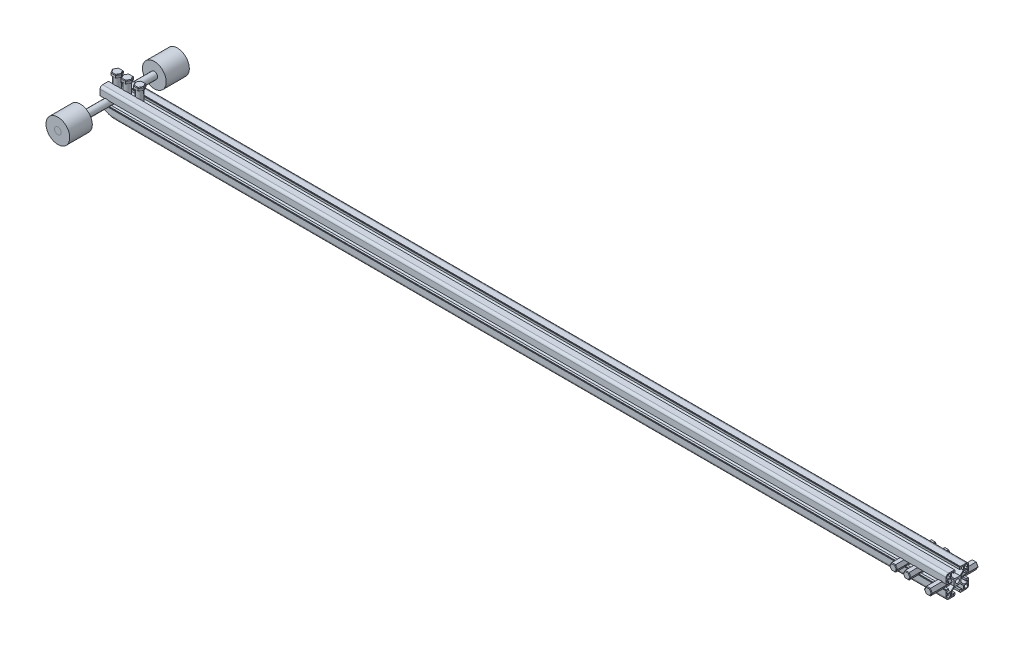
from build123d import *

# Parameters (mm, degrees)
SKETCH11_R                                     = 3.4
C_PROGRAM_FILES_SOLIDWORKS_CORP_SOLIDWOR_DEPTH = 2000
IZIM1_R                                        = 66.227131851
KES_EKSTR_ZYON1_DEPTH                          = 500
Y_KSEKLIK_EKSTR_ZYON2_START                    = -48
Y_KSEKLIK_EKSTR_ZYON2_DEPTH                    = 83
IZIM5_R                                        = 1
KES_EKSTR_ZYON2_DEPTH                          = 75
IZIM6_R                                        = 5.5
Y_KSEKLIK_EKSTR_ZYON3_DEPTH                    = 30
Y_KSEKLIK_EKSTR_ZYON4_START                    = -3
Y_KSEKLIK_EKSTR_ZYON4_DEPTH                    = 5
PAH1_SIZE                                      = 1
KES_EKSTR_ZYON3_DEPTH                          = 77
L_O_ALTMA1_COUNT                               = 2
L_O_ALTMA1_PITCH                               = 18
PAH2_SIZE                                      = 1
L_O_ALTMA2_COUNT                               = 2
L_O_ALTMA2_PITCH                               = 18
IZIM2_R                                        = 6
Y_KSEKLIK_EKSTR_ZYON5_DEPTH                    = 100
Y_KSEKLIK_EKSTR_ZYON5_DEPTH_BACK               = 112
Y_KSEKLIK_EKSTR_ZYON6_DEPTH                    = 30
Y_KSEKLIK_EKSTR_ZYON6_DEPTH_BACK               = 42
Y_KSEKLIK_EKSTR_ZYON6_2_DEPTH                  = 30
Y_KSEKLIK_EKSTR_ZYON6_2_DEPTH_BACK             = 42
PAH4_SIZE                                      = 1
PAH5_SIZE                                      = 1
PAH6_SIZE                                      = 1
PAH7_SIZE                                      = 1
PAH8_SIZE                                      = 1
IZIM10_R                                       = 21.05967532
Y_KSEKLIK_EKSTR_ZYON7_DEPTH                    = 41
IZIM11_R                                       = 21.05967532
Y_KSEKLIK_EKSTR_ZYON8_DEPTH                    = 40
L_O_ALTMA4_COUNT                               = 2
L_O_ALTMA4_PITCH                               = 40
L_O_ALTMA5_COUNT                               = 2
L_O_ALTMA5_PITCH                               = 40
PAH9_SIZE                                      = 1


with BuildPart() as part:
    # Sketch11 → C_PROGRAM FILES_SOLIDWORKS CORP_SOLIDWOR (new body)
    with BuildSketch(Plane.YZ):
        with BuildLine():
            Line((-6.137886111, 5.937531511), (3.033686764, 5.937531511))
            Line((3.033686764, 5.937531511), (8.847900326, 11.751745073))
            Line((8.847900326, 11.751745073), (8.847900326, 18.137531511))
            Line((8.847900326, 18.137531511), (5.706014433, 18.137531511))
            Line((5.706014433, 18.137531511), (5.706014433, 15.437531511))
            Line((5.706014433, 15.437531511), (2.547900326, 15.437531511))
            Line((2.547900326, 15.437531511), (2.547900326, 18.937531511))
            Line((2.547900326, 18.937531511), (3.547900326, 18.937531511))
            Line((3.547900326, 18.937531511), (3.547900326, 19.937531511))
            Line((3.547900326, 19.937531511), (13.947900326, 19.937531511))
            ThreePointArc((13.947900326, 19.937531511), (17.129880842, 18.619512026), (18.447900326, 15.437531511))
            Line((18.447900326, 15.437531511), (18.447900326, 5.037531511))
            Line((18.447900326, 5.037531511), (17.447900326, 5.037531511))
            Line((17.447900326, 5.037531511), (17.447900326, 4.037531511))
            Line((17.447900326, 4.037531511), (13.947900326, 4.037531511))
            Line((13.947900326, 4.037531511), (13.947900326, 7.037531511))
            Line((13.947900326, 7.037531511), (16.647900326, 7.037531511))
            Line((16.647900326, 7.037531511), (16.647900326, 10.337531511))
            Line((16.647900326, 10.337531511), (10.262113889, 10.337531511))
            Line((10.262113889, 10.337531511), (4.447900326, 4.523317948))
            Line((4.447900326, 4.523317948), (4.447900326, -4.648254927))
            Line((4.447900326, -4.648254927), (10.262113889, -10.462468489))
            Line((10.262113889, -10.462468489), (16.647900326, -10.462468489))
            Line((16.647900326, -10.462468489), (16.647900326, -7.162468489))
            Line((16.647900326, -7.162468489), (13.947900326, -7.162468489))
            Line((13.947900326, -7.162468489), (13.947900326, -4.162468489))
            Line((13.947900326, -4.162468489), (17.447900326, -4.162468489))
            Line((17.447900326, -4.162468489), (17.447900326, -5.162468489))
            Line((17.447900326, -5.162468489), (18.447900326, -5.162468489))
            Line((18.447900326, -5.162468489), (18.447900326, -15.562468489))
            ThreePointArc((18.447900326, -15.562468489), (17.129880842, -18.744449005), (13.947900326, -20.062468489))
            Line((13.947900326, -20.062468489), (3.547900326, -20.062468489))
            Line((3.547900326, -20.062468489), (3.547900326, -19.062468489))
            Line((3.547900326, -19.062468489), (2.547900326, -19.062468489))
            Line((2.547900326, -19.062468489), (2.547900326, -15.562468489))
            Line((2.547900326, -15.562468489), (5.706014433, -15.562468489))
            Line((5.706014433, -15.562468489), (5.706014433, -18.262468489))
            Line((5.706014433, -18.262468489), (8.847900326, -18.262468489))
            Line((8.847900326, -18.262468489), (8.847900326, -11.876682052))
            Line((8.847900326, -11.876682052), (3.033686764, -6.062468489))
            Line((3.033686764, -6.062468489), (-6.137886111, -6.062468489))
            Line((-6.137886111, -6.062468489), (-11.952099674, -11.876682052))
            Line((-11.952099674, -11.876682052), (-11.952099674, -18.262468489))
            Line((-11.952099674, -18.262468489), (-8.81021378, -18.262468489))
            Line((-8.81021378, -18.262468489), (-8.81021378, -15.562468489))
            Line((-8.81021378, -15.562468489), (-5.652099674, -15.562468489))
            Line((-5.652099674, -15.562468489), (-5.652099674, -19.062468489))
            Line((-5.652099674, -19.062468489), (-6.652099674, -19.062468489))
            Line((-6.652099674, -19.062468489), (-6.652099674, -20.062468489))
            Line((-6.652099674, -20.062468489), (-17.052099674, -20.062468489))
            ThreePointArc((-17.052099674, -20.062468489), (-20.234080189, -18.744449005), (-21.552099674, -15.562468489))
            Line((-21.552099674, -15.562468489), (-21.552099674, -5.162468489))
            Line((-21.552099674, -5.162468489), (-20.552099674, -5.162468489))
            Line((-20.552099674, -5.162468489), (-20.552099674, -4.162468489))
            Line((-20.552099674, -4.162468489), (-17.052099674, -4.162468489))
            Line((-17.052099674, -4.162468489), (-17.052099674, -7.162468489))
            Line((-17.052099674, -7.162468489), (-19.752099674, -7.162468489))
            Line((-19.752099674, -7.162468489), (-19.752099674, -10.462468489))
            Line((-19.752099674, -10.462468489), (-13.366313236, -10.462468489))
            Line((-13.366313236, -10.462468489), (-7.552099674, -4.648254927))
            Line((-7.552099674, -4.648254927), (-7.552099674, 4.523317948))
            Line((-7.552099674, 4.523317948), (-13.366313236, 10.337531511))
            Line((-13.366313236, 10.337531511), (-19.752099674, 10.337531511))
            Line((-19.752099674, 10.337531511), (-19.752099674, 7.037531511))
            Line((-19.752099674, 7.037531511), (-17.052099674, 7.037531511))
            Line((-17.052099674, 7.037531511), (-17.052099674, 4.037531511))
            Line((-17.052099674, 4.037531511), (-20.552099674, 4.037531511))
            Line((-20.552099674, 4.037531511), (-20.552099674, 5.037531511))
            Line((-20.552099674, 5.037531511), (-21.552099674, 5.037531511))
            Line((-21.552099674, 5.037531511), (-21.552099674, 15.437531511))
            ThreePointArc((-21.552099674, 15.437531511), (-20.234080189, 18.619512026), (-17.052099674, 19.937531511))
            Line((-17.052099674, 19.937531511), (-6.652099674, 19.937531511))
            Line((-6.652099674, 19.937531511), (-6.652099674, 18.937531511))
            Line((-6.652099674, 18.937531511), (-5.652099674, 18.937531511))
            Line((-5.652099674, 18.937531511), (-5.652099674, 15.437531511))
            Line((-5.652099674, 15.437531511), (-8.81021378, 15.437531511))
            Line((-8.81021378, 15.437531511), (-8.81021378, 18.137531511))
            Line((-8.81021378, 18.137531511), (-11.952099674, 18.137531511))
            Line((-11.952099674, 18.137531511), (-11.952099674, 11.751745073))
            Line((-11.952099674, 11.751745073), (-6.137886111, 5.937531511))
        make_face()
        with Locations((-1.552099674, -0.062468489)):
            Circle(SKETCH11_R, mode=Mode.SUBTRACT)
        with BuildLine():
            Line((16.647900326, 12.137531511), (10.647900326, 12.137531511))
            Line((10.647900326, 12.137531511), (10.647900326, 18.137531511))
            Line((10.647900326, 18.137531511), (13.947900326, 18.137531511))
            ThreePointArc((13.947900326, 18.137531511), (15.857088636, 17.34671982), (16.647900326, 15.437531511))
            Line((16.647900326, 15.437531511), (16.647900326, 12.137531511))
        make_face(mode=Mode.SUBTRACT)
        with BuildLine():
            Line((-19.752099674, 15.437531511), (-19.752099674, 12.137531511))
            Line((-19.752099674, 12.137531511), (-13.752099674, 12.137531511))
            Line((-13.752099674, 12.137531511), (-13.752099674, 18.137531511))
            Line((-13.752099674, 18.137531511), (-17.052099674, 18.137531511))
            ThreePointArc((-17.052099674, 18.137531511), (-18.961287983, 17.34671982), (-19.752099674, 15.437531511))
        make_face(mode=Mode.SUBTRACT)
        with BuildLine():
            Line((-19.752099674, -15.562468489), (-19.752099674, -12.262468489))
            Line((-19.752099674, -12.262468489), (-13.752099674, -12.262468489))
            Line((-13.752099674, -12.262468489), (-13.752099674, -18.262468489))
            Line((-13.752099674, -18.262468489), (-17.052099674, -18.262468489))
            ThreePointArc((-17.052099674, -18.262468489), (-18.961287983, -17.471656799), (-19.752099674, -15.562468489))
        make_face(mode=Mode.SUBTRACT)
        with BuildLine():
            Line((10.647900326, -18.262468489), (13.947900326, -18.262468489))
            ThreePointArc((13.947900326, -18.262468489), (15.857088636, -17.471656799), (16.647900326, -15.562468489))
            Line((16.647900326, -15.562468489), (16.647900326, -12.262468489))
            Line((16.647900326, -12.262468489), (10.647900326, -12.262468489))
            Line((10.647900326, -12.262468489), (10.647900326, -18.262468489))
        make_face(mode=Mode.SUBTRACT)
    extrude(amount=C_PROGRAM_FILES_SOLIDWORKS_CORP_SOLIDWOR_DEPTH)

    # izim1 → Kes-Ekstr_zyon1 (cut)
    with BuildSketch(Plane.ZY):
        Circle(IZIM1_R)
    extrude(amount=-KES_EKSTR_ZYON1_DEPTH, mode=Mode.SUBTRACT)


with BuildPart() as body_2:
    # izim4 → Y_kseklik-Ekstr_zyon2 (new body)
    with BuildSketch(Plane(origin=(0, 0, -6.062468489), x_dir=(-1, 0, 0), z_dir=(0, 0, -1)).offset(Y_KSEKLIK_EKSTR_ZYON2_START)):
        Polygon((-1982.78346991, -1.539078344), (-1986.201616223, 4.381324739), (-1993.037908851, 4.381324739), (-1996.456055164, -1.539078344), (-1993.037908851, -7.459481427), (-1986.201616223, -7.459481427), align=None)
    extrude(amount=Y_KSEKLIK_EKSTR_ZYON2_DEPTH)


with BuildPart() as kes_ekstr_zyon2_tool:
    # izim5 → Kes-Ekstr_zyon2 (new body)
    with BuildSketch(Plane(origin=(0, 0, -41.062468489), x_dir=(-1, 0, 0), z_dir=(0, 0, -1))):
        with Locations((-1989.491483003, -1.613140568)):
            Circle(IZIM5_R)
    extrude(amount=-KES_EKSTR_ZYON2_DEPTH)


with BuildPart() as part_1:
    add(part.part)

    # Kes-Ekstr_zyon2: cut by kes_ekstr_zyon2_tool
    add(kes_ekstr_zyon2_tool.part, mode=Mode.SUBTRACT)

    # izim8 → Kes-Ekstr_zyon3 (cut)
    with BuildSketch(Plane.XY.offset(19.937531511)):
        Polygon((485.060463918, -4.697219863), (533.905149902, -24.526704322), (480.540507902, -31.23373583), align=None)
    extrude(amount=-KES_EKSTR_ZYON3_DEPTH, mode=Mode.SUBTRACT)


with BuildPart() as body_2_1:
    add(body_2.part)

    # Kes-Ekstr_zyon2: cut by kes_ekstr_zyon2_tool
    add(kes_ekstr_zyon2_tool.part, mode=Mode.SUBTRACT)

    # Pah4
    pah4_edges = [body_2_1.edges().sort_by_distance(p)[0] for p in [
        (1989.619762537, 4.381324739, 41.937531511),
        (1994.746982007, 1.421123197, 41.937531511),
        (1984.492543067, -4.499279886, -41.062468489),
        (1984.492543067, 1.421123197, -41.062468489),
        (1989.619762537, 4.381324739, -41.062468489),
        (1994.746982007, 1.421123197, -41.062468489),
        (1994.746982007, -4.499279886, -41.062468489),
        (1989.619762537, -7.459481427, -41.062468489),
        (1994.746982007, -4.499279886, 41.937531511),
        (1989.619762537, -7.459481427, 41.937531511),
        (1990.491483003, -1.613140568, -41.062468489),
        (1984.492543067, -4.499279886, 41.937531511),
        (1984.492543067, 1.421123197, 41.937531511),
    ]]
    chamfer(pah4_edges, length=PAH4_SIZE)


with BuildPart() as body_3:
    # izim6 → Y_kseklik-Ekstr_zyon3 (new body)
    with BuildSketch(Plane(origin=(0, 4.447900326, 0), x_dir=(1, 0, 0), z_dir=(0, 1, 0))):
        with Locations(Location((510.216722253, 0, 0), (0, 0, 270))):
            Circle(IZIM6_R)
    y_kseklik_ekstr_zyon3 = extrude(amount=Y_KSEKLIK_EKSTR_ZYON3_DEPTH)


with BuildPart() as body_4:
    # izim7 → Y_kseklik-Ekstr_zyon4 (new body)
    with BuildSketch(Plane(origin=(0, 34.447900326, 0), x_dir=(1, 0, 0), z_dir=(0, 1, 0)).offset(Y_KSEKLIK_EKSTR_ZYON4_START)):
        Polygon((518.35987787, 0), (514.288300061, 7.052179631), (506.145144444, 7.052179631), (502.073566636, 0), (506.145144444, -7.052179631), (514.288300061, -7.052179631), align=None)
    y_kseklik_ekstr_zyon4 = extrude(amount=Y_KSEKLIK_EKSTR_ZYON4_DEPTH)

    # Pah1
    pah1_edges = [body_4.edges().sort_by_distance(p)[0] for p in [
        (516.324088965, 36.447900326, 3.526089816),
        (516.324088965, 36.447900326, -3.526089816),
        (510.216722253, 36.447900326, -7.052179631),
        (504.10935554, 36.447900326, -3.526089816),
        (504.10935554, 36.447900326, 3.526089816),
        (510.216722253, 36.447900326, 7.052179631),
    ]]
    chamfer(pah1_edges, length=PAH1_SIZE)


with BuildPart() as l_o_altma1_1:
    # L_o_altma1: Y_kseklik-Ekstr_zyon4 ×2
    with Locations(*[(i * L_O_ALTMA1_PITCH, 0, 0) for i in range(1, L_O_ALTMA1_COUNT)]):
        add(y_kseklik_ekstr_zyon4)

    # Pah2
    pah2_edges = [l_o_altma1_1.edges().sort_by_distance(p)[0] for p in [
        (534.324088965, 36.447900326, 3.526089816),
        (534.324088965, 36.447900326, -3.526089816),
        (528.216722253, 36.447900326, -7.052179631),
        (522.10935554, 36.447900326, -3.526089816),
        (522.10935554, 36.447900326, 3.526089816),
        (528.216722253, 36.447900326, 7.052179631),
    ]]
    chamfer(pah2_edges, length=PAH2_SIZE)


with BuildPart() as l_o_altma2_1:
    # L_o_altma2: Y_kseklik-Ekstr_zyon3 ×2
    with Locations(*[(i * L_O_ALTMA2_PITCH, 0, 0) for i in range(1, L_O_ALTMA2_COUNT)]):
        add(y_kseklik_ekstr_zyon3)


with BuildPart() as body_7:
    # izim2 → Y_kseklik-Ekstr_zyon5 (new, two sides)
    with BuildSketch(Plane(origin=(0, 0, -6.062468489), x_dir=(-1, 0, 0), z_dir=(0, 0, -1))) as y_kseklik_ekstr_zyon5_sk:
        with Locations((-511.206146485, -1.552099674)):
            Circle(IZIM2_R)
    extrude(amount=Y_KSEKLIK_EKSTR_ZYON5_DEPTH)
    extrude(y_kseklik_ekstr_zyon5_sk.sketch, amount=-Y_KSEKLIK_EKSTR_ZYON5_DEPTH_BACK)


with BuildPart() as body_8:
    # izim9 → Y_kseklik-Ekstr_zyon6 (new, two sides)
    with BuildSketch(Plane(origin=(0, 0, -6.062468489), x_dir=(-1, 0, 0), z_dir=(0, 0, -1))) as y_kseklik_ekstr_zyon6_sk:
        Polygon((-1939.240914281, -1.912378723), (-1942.62045714, 3.941161216), (-1949.37954286, 3.941161216), (-1952.759085719, -1.912378723), (-1949.37954286, -7.765918662), (-1942.62045714, -7.765918662), align=None)
    extrude(amount=Y_KSEKLIK_EKSTR_ZYON6_DEPTH)
    extrude(y_kseklik_ekstr_zyon6_sk.sketch, amount=-Y_KSEKLIK_EKSTR_ZYON6_DEPTH_BACK)

    # Pah5
    pah5_edges = [body_8.edges().sort_by_distance(p)[0] for p in [
        (1946, 3.941161216, 35.937531511),
        (1951.069314289, 1.014391247, 35.937531511),
        (1951.069314289, -4.839148693, 35.937531511),
        (1946, -7.765918662, 35.937531511),
        (1940.930685711, -4.839148693, 35.937531511),
        (1940.930685711, 1.014391247, 35.937531511),
    ]]
    chamfer(pah5_edges, length=PAH5_SIZE)

    # Pah8
    pah8_edges = [body_8.edges().sort_by_distance(p)[0] for p in [
        (1940.930685711, -4.839148693, -36.062468489),
        (1940.930685711, 1.014391247, -36.062468489),
        (1946, 3.941161216, -36.062468489),
        (1951.069314289, 1.014391247, -36.062468489),
        (1951.069314289, -4.839148693, -36.062468489),
        (1946, -7.765918662, -36.062468489),
    ]]
    chamfer(pah8_edges, length=PAH8_SIZE)


with BuildPart() as body_9:
    # izim9 → Y_kseklik-Ekstr_zyon6 2 (new, two sides)
    with BuildSketch(Plane(origin=(0, 0, -6.062468489), x_dir=(-1, 0, 0), z_dir=(0, 0, -1))) as y_kseklik_ekstr_zyon6_2_sk:
        Polygon((-1915.240914281, -1.912378723), (-1918.62045714, 3.941161216), (-1925.37954286, 3.941161216), (-1928.759085719, -1.912378723), (-1925.37954286, -7.765918662), (-1918.62045714, -7.765918662), align=None)
    extrude(amount=Y_KSEKLIK_EKSTR_ZYON6_2_DEPTH)
    extrude(y_kseklik_ekstr_zyon6_2_sk.sketch, amount=-Y_KSEKLIK_EKSTR_ZYON6_2_DEPTH_BACK)

    # Pah6
    pah6_edges = [body_9.edges().sort_by_distance(p)[0] for p in [
        (1922, 3.941161216, 35.937531511),
        (1927.069314289, 1.014391247, 35.937531511),
        (1927.069314289, -4.839148693, 35.937531511),
        (1922, -7.765918662, 35.937531511),
        (1916.930685711, -4.839148693, 35.937531511),
        (1916.930685711, 1.014391247, 35.937531511),
    ]]
    chamfer(pah6_edges, length=PAH6_SIZE)

    # Pah7
    pah7_edges = [body_9.edges().sort_by_distance(p)[0] for p in [
        (1916.930685711, -4.839148693, -36.062468489),
        (1916.930685711, 1.014391247, -36.062468489),
        (1922, 3.941161216, -36.062468489),
        (1927.069314289, 1.014391247, -36.062468489),
        (1927.069314289, -4.839148693, -36.062468489),
        (1922, -7.765918662, -36.062468489),
    ]]
    chamfer(pah7_edges, length=PAH7_SIZE)


with BuildPart() as body_10:
    # izim10 → Y_kseklik-Ekstr_zyon7 (new body)
    with BuildSketch(Plane(origin=(0, 0, -106.062468489), x_dir=(-1, 0, 0), z_dir=(0, 0, -1))):
        with Locations((-511.206146485, -1.552099674)):
            Circle(IZIM10_R)
    extrude(amount=-Y_KSEKLIK_EKSTR_ZYON7_DEPTH)


with BuildPart() as body_11:
    # izim11 → Y_kseklik-Ekstr_zyon8 (new body)
    with BuildSketch(Plane.XY.offset(105.937531511)):
        with Locations((511.206146485, -1.552099674)):
            Circle(IZIM11_R)
    extrude(amount=-Y_KSEKLIK_EKSTR_ZYON8_DEPTH)


with BuildPart() as l_o_altma4_1:
    # L_o_altma4: Y_kseklik-Ekstr_zyon3 ×2
    with Locations(*[(i * L_O_ALTMA4_PITCH, 0, 0) for i in range(1, L_O_ALTMA4_COUNT)]):
        add(y_kseklik_ekstr_zyon3)


with BuildPart() as l_o_altma5_1:
    # L_o_altma5: Y_kseklik-Ekstr_zyon4 ×2
    with Locations(*[(i * L_O_ALTMA5_PITCH, 0, 0) for i in range(1, L_O_ALTMA5_COUNT)]):
        add(y_kseklik_ekstr_zyon4)

    # Pah9
    pah9_edges = [l_o_altma5_1.edges().sort_by_distance(p)[0] for p in [
        (556.324088965, 36.447900326, 3.526089816),
        (556.324088965, 36.447900326, -3.526089816),
        (550.216722253, 36.447900326, -7.052179631),
        (544.10935554, 36.447900326, -3.526089816),
        (544.10935554, 36.447900326, 3.526089816),
        (550.216722253, 36.447900326, 7.052179631),
    ]]
    chamfer(pah9_edges, length=PAH9_SIZE)


solid = Compound([part_1.part, body_2_1.part, body_3.part, body_4.part, l_o_altma1_1.part, l_o_altma2_1.part, body_7.part, body_8.part, body_9.part, body_10.part, body_11.part, l_o_altma4_1.part, l_o_altma5_1.part])
